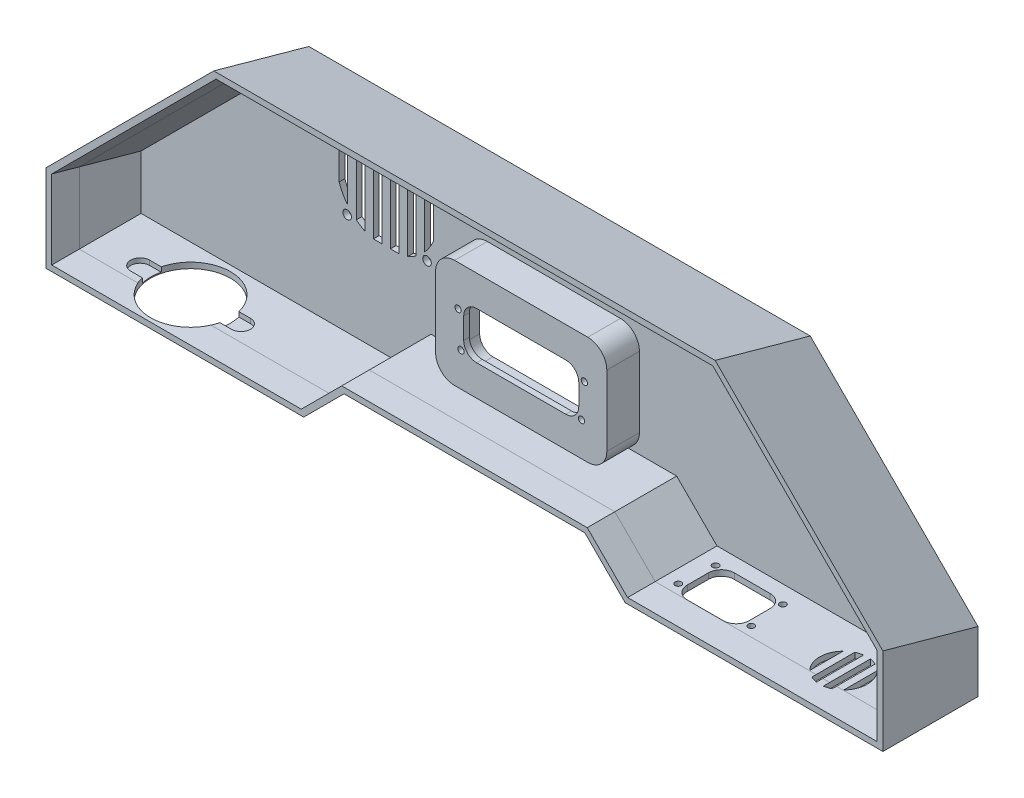
from build123d import *

# Parameters (mm, degrees)
SHELL1_T            = -3
SKETCH3_R           = 1.65
CUT_EXTRUDE1_DEPTH  = 4.0000001
SKETCH4_W           = 4.5
SKETCH4_H           = 25.15
SKETCH4_R           = 2.25
CUT_EXTRUDE2_DEPTH  = 4.0000001
BOSS_EXTRUDE1_DEPTH = 17.15
CUT_EXTRUDE3_DEPTH  = 17.15
SKETCH9_R           = 1.65
CUT_EXTRUDE4_DEPTH  = 3
CUT_EXTRUDE5_DEPTH  = 3
SKETCH11_R          = 21
CUT_EXTRUDE9_DEPTH  = 3
SKETCH15_R          = 5
CUT_EXTRUDE10_DEPTH = 2.46


with BuildPart() as part:
    # Sketch1 → Loft1 section 0
    with BuildSketch(Plane.XY):
        Polygon((-131.798989871, -8), (131.798989871, -8), (219.999999995, -96.201010124), (219.999999995, -142), (84.526911935, -142), (63.313708499, -120.786796564), (-63.313708499, -120.786796564), (-84.526911935, -142), (-219.999999995, -142), (-219.999999995, -96.201010124), align=None)
    # Sketch2 → Loft1 section 1
    with BuildSketch(Plane.XY.offset(-50)):
        Polygon((84.526911935, -142), (219.999999995, -142), (219.999999995, -110.084496369), (131.798989871, -21.883486245), (-131.798989871, -21.883486245), (-219.999999995, -110.084496369), (-219.999999995, -142), (-84.526911935, -142), (-63.313708499, -120.786796564), (63.313708499, -120.786796564), align=None)
    loft()

    # Shell1
    shell1_openings = [part.faces().sort_by_distance(p)[0] for p in [
        (0, -101.797561338, 0),
    ]]
    offset(amount=SHELL1_T, openings=shell1_openings, kind=Kind.INTERSECTION)

    # Sketch3 → Cut-Extrude1 (cut, through all)
    with BuildSketch(Plane(origin=(0, -139, 5.432952069), x_dir=(1, 0, 0), z_dir=(0, 1, 0))):
        with Locations((94.299999995, 43.132952069)):
            Circle(SKETCH3_R)
        with Locations((129.699999995, 43.132952069)):
            Circle(SKETCH3_R)
        with Locations((92.799999995, 25.032952069)):
            Circle(SKETCH3_R)
        with Locations((131.199999995, 25.032952069)):
            Circle(SKETCH3_R)
        with BuildLine():
            Line((102.549999995, 44.732952069), (121.449999995, 44.732952069))
            ThreePointArc((121.449999995, 44.732952069), (126.258326107, 42.741278181), (128.249999995, 37.932952069))
            Line((128.249999995, 37.932952069), (128.249999995, 26.832952069))
            ThreePointArc((128.249999995, 26.832952069), (126.258326107, 22.024625957), (121.449999995, 20.032952069))
            Line((121.449999995, 20.032952069), (102.549999995, 20.032952069))
            ThreePointArc((102.549999995, 20.032952069), (97.741673883, 22.024625957), (95.749999995, 26.832952069))
            Line((95.749999995, 26.832952069), (95.749999995, 37.932952069))
            ThreePointArc((95.749999995, 37.932952069), (97.741673883, 42.741278181), (102.549999995, 44.732952069))
        make_face()
    extrude(amount=-CUT_EXTRUDE1_DEPTH, mode=Mode.SUBTRACT)

    # Sketch4 → Cut-Extrude2 (cut, through all)
    with BuildSketch(Plane.XY.offset(-47)):
        with BuildLine():
            Line((-112.88306325, -56.201396063), (-112.88306325, -64.399566591))
            Line((-112.88306325, -64.399566591), (-108.38306325, -64.399566591))
            Line((-108.38306325, -64.399566591), (-108.38306325, -47.853872287))
            ThreePointArc((-108.38306325, -47.853872287), (-111.009502934, -51.82470231), (-112.88306325, -56.201396063))
        make_face()
        with BuildLine():
            Line((-108.38306325, -64.399566591), (-112.88306325, -64.399566591))
            Line((-112.88306325, -64.399566591), (-112.88306325, -72.597737119))
            ThreePointArc((-112.88306325, -72.597737119), (-111.009502934, -76.974430873), (-108.38306325, -80.945260895))
            Line((-108.38306325, -80.945260895), (-108.38306325, -64.399566591))
        make_face()
        with BuildLine():
            Line((-103.88306325, -43.427919064), (-103.88306325, -64.399566591))
            Line((-103.88306325, -64.399566591), (-99.38306325, -64.399566591))
            Line((-99.38306325, -64.399566591), (-99.38306325, -40.622266492))
            ThreePointArc((-99.38306325, -40.622266492), (-101.703420649, -41.912246199), (-103.88306325, -43.427919064))
        make_face()
        with BuildLine():
            Line((-99.38306325, -64.399566591), (-103.88306325, -64.399566591))
            Line((-103.88306325, -64.399566591), (-103.88306325, -85.371214118))
            ThreePointArc((-103.88306325, -85.371214118), (-101.703420649, -86.886886983), (-99.38306325, -88.17686669))
            Line((-99.38306325, -88.17686669), (-99.38306325, -64.399566591))
        make_face()
        with Locations((-92.63306325, -51.824566591)):
            Rectangle(SKETCH4_W, SKETCH4_H)
        with Locations((-92.63306325, -76.974566591)):
            Rectangle(SKETCH4_W, SKETCH4_H)
        with Locations((-83.63306325, -51.824566591)):
            Rectangle(SKETCH4_W, SKETCH4_H)
        with Locations((-83.63306325, -76.974566591)):
            Rectangle(SKETCH4_W, SKETCH4_H)
        with BuildLine():
            Line((-76.88306325, -40.200186434), (-76.88306325, -64.399566591))
            Line((-76.88306325, -64.399566591), (-72.38306325, -64.399566591))
            Line((-72.38306325, -64.399566591), (-72.38306325, -42.762561253))
            ThreePointArc((-72.38306325, -42.762561253), (-74.570323599, -41.371191511), (-76.88306325, -40.200186434))
        make_face()
        with BuildLine():
            Line((-72.38306325, -64.399566591), (-76.88306325, -64.399566591))
            Line((-76.88306325, -64.399566591), (-76.88306325, -88.598946748))
            ThreePointArc((-76.88306325, -88.598946748), (-74.570323599, -87.427941671), (-72.38306325, -86.036571929))
            Line((-72.38306325, -86.036571929), (-72.38306325, -64.399566591))
        make_face()
        with BuildLine():
            Line((-67.88306325, -46.78678714), (-67.88306325, -64.399566591))
            Line((-67.88306325, -64.399566591), (-63.38306325, -64.399566591))
            Line((-63.38306325, -64.399566591), (-63.38306325, -53.827906362))
            ThreePointArc((-63.38306325, -53.827906362), (-65.353781131, -50.128856727), (-67.88306325, -46.78678714))
        make_face()
        with BuildLine():
            Line((-63.38306325, -64.399566591), (-67.88306325, -64.399566591))
            Line((-67.88306325, -64.399566591), (-67.88306325, -82.012346042))
            ThreePointArc((-67.88306325, -82.012346042), (-65.353781131, -78.670276455), (-63.38306325, -74.97122682))
            Line((-63.38306325, -74.97122682), (-63.38306325, -64.399566591))
        make_face()
        with Locations((-108.68306325, -43.399566591)):
            Circle(SKETCH4_R)
        with Locations((-66.68306325, -43.399566591)):
            Circle(SKETCH4_R)
        with Locations((-66.68306325, -85.399566591)):
            Circle(SKETCH4_R)
        with Locations((-108.68306325, -85.399566591)):
            Circle(SKETCH4_R)
    extrude(amount=-CUT_EXTRUDE2_DEPTH, mode=Mode.SUBTRACT)

    # Sketch6 → Boss-Extrude1 (add)
    with BuildSketch(Plane.XY.offset(-47)):
        with BuildLine():
            Line((-35, -60.786796564), (35, -60.786796564))
            ThreePointArc((35, -60.786796564), (42.071067812, -63.715728753), (45, -70.786796564))
            Line((45, -70.786796564), (45, -107.786796564))
            ThreePointArc((45, -107.786796564), (42.071067812, -114.857864376), (35, -117.786796564))
            Line((35, -117.786796564), (-35, -117.786796564))
            ThreePointArc((-35, -117.786796564), (-42.071067812, -114.857864376), (-45, -107.786796564))
            Line((-45, -107.786796564), (-45, -70.786796564))
            ThreePointArc((-45, -70.786796564), (-42.071067812, -63.715728753), (-35, -60.786796564))
        make_face()
    extrude(amount=BOSS_EXTRUDE1_DEPTH)

    # Sketch8 → Cut-Extrude3 (cut)
    with BuildSketch(Plane(origin=(0, 0, -50), x_dir=(-1, 0, 0), z_dir=(0, 0, -1))):
        with BuildLine():
            Line((-42, -70.786796564), (-42, -107.786796564))
            ThreePointArc((-42, -107.786796564), (-39.949747468, -112.736544033), (-35, -114.786796564))
            Line((-35, -114.786796564), (35, -114.786796564))
            ThreePointArc((35, -114.786796564), (39.949747468, -112.736544033), (42, -107.786796564))
            Line((42, -107.786796564), (42, -70.786796564))
            ThreePointArc((42, -70.786796564), (39.949747468, -65.837049096), (35, -63.786796564))
            Line((35, -63.786796564), (-35, -63.786796564))
            ThreePointArc((-35, -63.786796564), (-39.949747468, -65.837049096), (-42, -70.786796564))
        make_face()
    extrude(amount=-CUT_EXTRUDE3_DEPTH, mode=Mode.SUBTRACT)

    # Sketch9 → Cut-Extrude4 (cut)
    with BuildSketch(Plane(origin=(0, 0, -32.85), x_dir=(-1, 0, 0), z_dir=(0, 0, -1))):
        with Locations((-33.2, -81.936796564)):
            Circle(SKETCH9_R)
        with Locations((-31.7, -100.036796564)):
            Circle(SKETCH9_R)
        with Locations((33.2, -81.936796564)):
            Circle(SKETCH9_R)
        with Locations((31.7, -100.036796564)):
            Circle(SKETCH9_R)
        with BuildLine():
            Line((-23.45, -76.936796564), (23.45, -76.936796564))
            ThreePointArc((23.45, -76.936796564), (28.258326112, -78.928470452), (30.25, -83.736796564))
            Line((30.25, -83.736796564), (30.25, -94.836796564))
            ThreePointArc((30.25, -94.836796564), (28.258326112, -99.645122676), (23.45, -101.636796564))
            Line((23.45, -101.636796564), (-23.45, -101.636796564))
            ThreePointArc((-23.45, -101.636796564), (-28.258326112, -99.645122676), (-30.25, -94.836796564))
            Line((-30.25, -94.836796564), (-30.25, -83.736796564))
            ThreePointArc((-30.25, -83.736796564), (-28.258326112, -78.928470452), (-23.45, -76.936796564))
        make_face()
    extrude(amount=-CUT_EXTRUDE4_DEPTH, mode=Mode.SUBTRACT)

    # Sketch10 → Cut-Extrude5 (cut)
    with BuildSketch(Plane(origin=(0, -139, 0), x_dir=(1, 0, 0), z_dir=(0, 1, 0))):
        with BuildLine():
            ThreePointArc((166.840981193, 32.248177653), (163.269552622, 23.5), (166.840981193, 14.751822347))
            Line((166.840981193, 14.751822347), (166.840981193, 32.248177653))
        make_face()
        with BuildLine():
            Line((170.412409765, 34.793848786), (170.412409765, 12.206151214))
            ThreePointArc((170.412409765, 12.206151214), (172.157684386, 11.533195588), (173.983838336, 11.128208517))
            Line((173.983838336, 11.128208517), (173.983838336, 35.871791483))
            ThreePointArc((173.983838336, 35.871791483), (172.157684386, 35.466804412), (170.412409765, 34.793848786))
        make_face()
        with BuildLine():
            Line((177.555266907, 35.871791483), (177.555266907, 11.128208517))
            ThreePointArc((177.555266907, 11.128208517), (179.381420858, 11.533195588), (181.126695479, 12.206151214))
            Line((181.126695479, 12.206151214), (181.126695479, 34.793848786))
            ThreePointArc((181.126695479, 34.793848786), (179.381420858, 35.466804412), (177.555266907, 35.871791483))
        make_face()
        with BuildLine():
            Line((184.69812405, 32.248177653), (184.69812405, 14.751822347))
            ThreePointArc((184.69812405, 14.751822347), (187.342303869, 18.775444087), (188.269552622, 23.5))
            ThreePointArc((188.269552622, 23.5), (187.342303869, 28.224555913), (184.69812405, 32.248177653))
        make_face()
    extrude(amount=-CUT_EXTRUDE5_DEPTH, mode=Mode.SUBTRACT)

    # Sketch11 → Cut-Extrude9 (cut)
    with BuildSketch(Plane(origin=(0, -139, 0), x_dir=(1, 0, 0), z_dir=(0, 1, 0))):
        with Locations((-166.999999995, 23)):
            Circle(SKETCH11_R)
    extrude(amount=-CUT_EXTRUDE9_DEPTH, mode=Mode.SUBTRACT)

    # Sketch15 → Cut-Extrude10 (cut)
    with BuildSketch(Plane(origin=(0, -139, 0), x_dir=(1, 0, 0), z_dir=(0, 1, 0))):
        with BuildLine():
            Line((-187.999999995, 23), (-187.999999995, 28))
            Line((-187.999999995, 28), (-193.499999995, 28))
            ThreePointArc((-193.499999995, 28), (-189.964466089, 26.535533906), (-188.499999995, 23))
            ThreePointArc((-188.499999995, 23), (-189.964466089, 19.464466094), (-193.499999995, 18))
            Line((-193.499999995, 18), (-187.999999995, 18))
            Line((-187.999999995, 18), (-187.999999995, 23))
        make_face()
        with Locations((-193.499999995, 23)):
            Circle(SKETCH15_R)
        with Locations((-140.499999995, 23)):
            Circle(SKETCH15_R)
        with BuildLine():
            Line((-140.499999995, 28), (-145.999999995, 28))
            Line((-145.999999995, 28), (-145.999999995, 23))
            Line((-145.999999995, 23), (-145.999999995, 18))
            Line((-145.999999995, 18), (-140.499999995, 18))
            ThreePointArc((-140.499999995, 18), (-145.499999995, 23), (-140.499999995, 28))
        make_face()
        with BuildLine():
            ThreePointArc((-145.999999995, 23), (-146.151527159, 20.481829944), (-146.60392194, 18))
            Line((-146.60392194, 18), (-145.999999995, 18))
            Line((-145.999999995, 18), (-145.999999995, 23))
        make_face()
        with BuildLine():
            Line((-145.999999995, 28), (-146.60392194, 28))
            ThreePointArc((-146.60392194, 28), (-146.151527159, 25.518170056), (-145.999999995, 23))
            Line((-145.999999995, 23), (-145.999999995, 28))
        make_face()
        with BuildLine():
            ThreePointArc((-187.396078049, 18), (-187.84847283, 20.481829944), (-187.999999995, 23))
            Line((-187.999999995, 23), (-187.999999995, 18))
            Line((-187.999999995, 18), (-187.396078049, 18))
        make_face()
        with BuildLine():
            Line((-187.396078049, 28), (-187.999999995, 28))
            Line((-187.999999995, 28), (-187.999999995, 23))
            ThreePointArc((-187.999999995, 23), (-187.84847283, 25.518170056), (-187.396078049, 28))
        make_face()
    extrude(amount=-CUT_EXTRUDE10_DEPTH, mode=Mode.SUBTRACT)


solid = part.part
